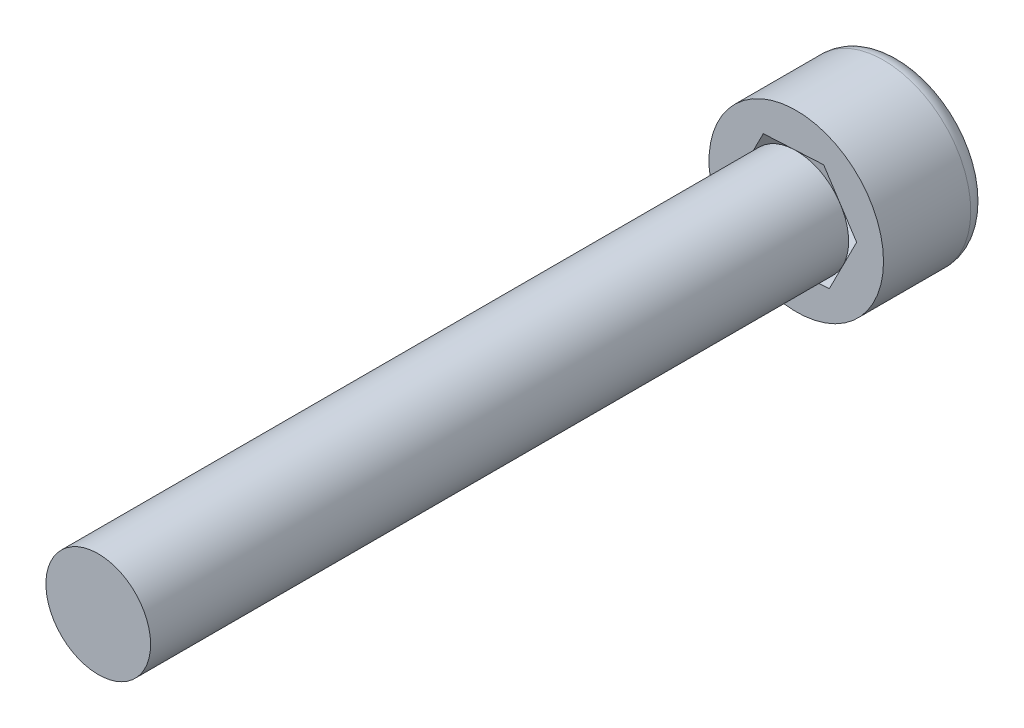
from build123d import *

# Parameters (mm, degrees)
SKETCH1_R           = 2.5
BOSS_EXTRUDE1_DEPTH = 3
SKETCH2_R           = 1.5
BOSS_EXTRUDE2_DEPTH = 20
CUT_EXTRUDE1_DEPTH  = 3
FILLET1_R           = 0.5


with BuildPart() as part:
    # Sketch1 → Boss-Extrude1 (new body)
    with BuildSketch(Plane.XY):
        Circle(SKETCH1_R)
    extrude(amount=BOSS_EXTRUDE1_DEPTH)

    # Sketch2 → Boss-Extrude2 (add)
    with BuildSketch(Plane.XY.offset(3)):
        Circle(SKETCH2_R)
    extrude(amount=BOSS_EXTRUDE2_DEPTH)

    # Sketch3 → Cut-Extrude1 (cut)
    with BuildSketch(Plane(origin=(0, 0, 0), x_dir=(-1, 0, 0), z_dir=(0, 0, -1))):
        Polygon((0.784462107, -1.544221229), (1.729565866, -0.092746502), (0.94510376, 1.451474727), (-0.784462107, 1.544221229), (-1.729565866, 0.092746502), (-0.94510376, -1.451474727), align=None)
    extrude(amount=-CUT_EXTRUDE1_DEPTH, mode=Mode.SUBTRACT)

    # Fillet1
    fillet1_edges = [part.edges().sort_by_distance(p)[0] for p in [
        (-2.5, 0, 0),
    ]]
    fillet(fillet1_edges, radius=FILLET1_R)


solid = part.part
